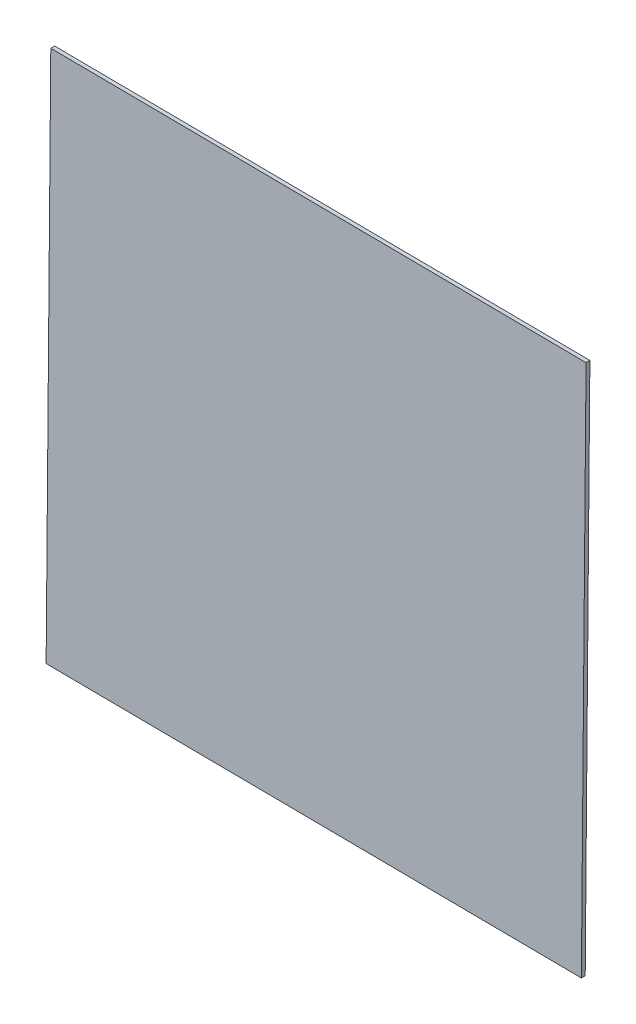
from build123d import *

# Parameters (mm, degrees)
BOSS_EXTRUDE1_DEPTH = 0.127


with BuildPart() as part:
    # Sketch1 → Boss-Extrude1 (new body)
    with BuildSketch(Plane.XY):
        Polygon((-97.559905217, 73.96561971), (-97.71461971, 56.237094783), (-79.986094783, 56.08238029), (-79.83138029, 73.810905217), align=None)
    extrude(amount=BOSS_EXTRUDE1_DEPTH)


solid = part.part
